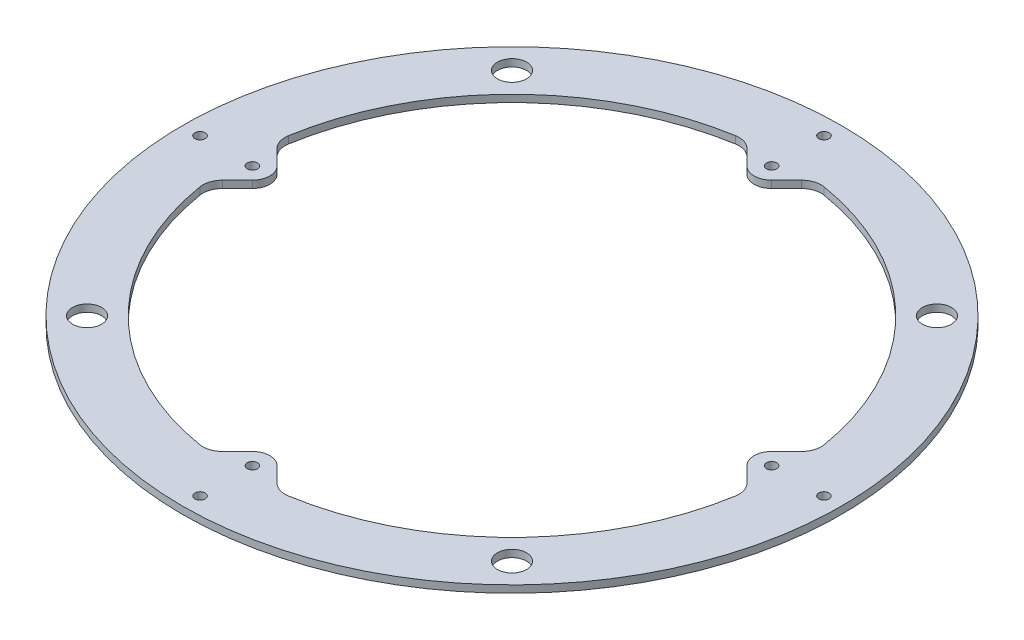
from build123d import *

# Parameters (mm, degrees)
SKETCH1_R                        = 215.9
SKETCH1_R_2                      = 177.8
BOSS_EXTRUDE1_DEPTH              = 4.7498
BOSS_EXTRUDE2_DEPTH              = 4.7498
FILLET2_R                        = 12.7
FILLET3_R                        = 11.43
F_1_4_CLEARANCE_HOLE1_AT_2_COUNT = 2
F_1_4_CLEARANCE_HOLE1_AT_2_PITCH = 34.29
CIRPATTERN1_COUNT                = 4
FILLET2_OF_CIRPATTERN1_R         = 12.7
FILLET3_OF_CIRPATTERN1_R         = 11.43
SKETCH6_R                        = 9.525
CUT_EXTRUDE1_DEPTH               = 4.7498
CIRPATTERN2_COUNT                = 4


with BuildPart() as part:
    # Sketch1 → Boss-Extrude1 (new body)
    with BuildSketch(Plane(origin=(0, 0, 0), x_dir=(1, 0, 0), z_dir=(0, 1, 0))):
        Circle(SKETCH1_R)
        Circle(SKETCH1_R_2, mode=Mode.SUBTRACT)
    extrude(amount=BOSS_EXTRUDE1_DEPTH)

    # Sketch3 → Boss-Extrude2 (add)
    with BuildSketch(Plane(origin=(0, 0, 0), x_dir=(1, 0, 0), z_dir=(0, 1, 0))):
        with BuildLine():
            Line((-22.450640303, 176.376894037), (0, 153.926253734))
            Line((0, 153.926253734), (22.450640303, 176.376894037))
            ThreePointArc((22.450640303, 176.376894037), (0, 177.8), (-22.450640303, 176.376894037))
        make_face()
    boss_extrude2 = extrude(amount=BOSS_EXTRUDE2_DEPTH)

    # Fillet2
    fillet2_edges = [part.edges().sort_by_distance(p)[0] for p in [
        (22.450640303, 2.3749, -176.376894037),
        (-22.450640303, 2.3749, -176.376894037),
    ]]
    fillet(fillet2_edges, radius=FILLET2_R)

    # Fillet3
    fillet3_edges = [part.edges().sort_by_distance(p)[0] for p in [
        (0, 2.3749, -153.926253734),
    ]]
    fillet(fillet3_edges, radius=FILLET3_R)

    # Sketch5 → 1/4 Clearance Hole1 (revolve, cut)
    with BuildSketch(Plane(origin=(0, 4.7498, -170.090714752), x_dir=(0, 0, 1), z_dir=(1, 0, 0))):
        Polygon((0, 0), (0, 12.189827343), (3.3782, 10.16), (3.3782, 0), align=None)
    f_1_4_clearance_hole1 = revolve(axis=Axis((0, 11.0998, -170.090714752), (0, -1, 0)), mode=Mode.SUBTRACT)

    # 1/4 Clearance Hole1 at 2: 1/4 Clearance Hole1 ×2
    with Locations(*[(0, 0, -i * F_1_4_CLEARANCE_HOLE1_AT_2_PITCH) for i in range(1, F_1_4_CLEARANCE_HOLE1_AT_2_COUNT)]):
        add(f_1_4_clearance_hole1, mode=Mode.SUBTRACT)

    # CirPattern1: Boss-Extrude2, 1/4 Clearance Hole1 ×4 about axis
    cirpattern1_axis = Axis((0, 0, 0), (0, 1, 0))
    for i in range(1, CIRPATTERN1_COUNT):
        add(boss_extrude2.rotate(cirpattern1_axis, i * 360 / CIRPATTERN1_COUNT))
        add(f_1_4_clearance_hole1.rotate(cirpattern1_axis, i * 360 / CIRPATTERN1_COUNT), mode=Mode.SUBTRACT)

    # CirPattern1 copy 1 sketch → CirPattern1 copy 1 (revolve, cut)
    with BuildSketch(Plane(origin=(-204.380714752, 4.7498, 0), x_dir=(1, 0, 0), z_dir=(0, 0, -1))):
        Polygon((0, 0), (0, 12.189827343), (3.3782, 10.16), (3.3782, 0), align=None)
    revolve(axis=Axis((-204.380714752, 11.0998, 0), (0, -1, 0)), mode=Mode.SUBTRACT)

    # CirPattern1 copy 2 sketch → CirPattern1 copy 2 (revolve, cut)
    with BuildSketch(Plane(origin=(0, 4.7498, 204.380714752), x_dir=(0, 0, -1), z_dir=(-1, 0, 0))):
        Polygon((0, 0), (0, 12.189827343), (3.3782, 10.16), (3.3782, 0), align=None)
    revolve(axis=Axis((0, 11.0998, 204.380714752), (0, -1, 0)), mode=Mode.SUBTRACT)

    # CirPattern1 copy 3 sketch → CirPattern1 copy 3 (revolve, cut)
    with BuildSketch(Plane(origin=(204.380714752, 4.7498, 0), x_dir=(-1, 0, 0), z_dir=(0, 0, 1))):
        Polygon((0, 0), (0, 12.189827343), (3.3782, 10.16), (3.3782, 0), align=None)
    revolve(axis=Axis((204.380714752, 11.0998, 0), (0, -1, 0)), mode=Mode.SUBTRACT)

    # Fillet2 of CirPattern1
    fillet2_of_cirpattern1_edges = [part.edges().sort_by_distance(p)[0] for p in [
        (-176.376894037, 2.3749, -22.450640303),
        (-176.376894037, 2.3749, 22.450640303),
        (-22.450640303, 2.3749, 176.376894037),
        (22.450640303, 2.3749, 176.376894037),
        (176.376894037, 2.3749, 22.450640303),
        (176.376894037, 2.3749, -22.450640303),
    ]]
    fillet(fillet2_of_cirpattern1_edges, radius=FILLET2_OF_CIRPATTERN1_R)

    # Fillet3 of CirPattern1
    fillet3_of_cirpattern1_edges = [part.edges().sort_by_distance(p)[0] for p in [
        (-153.926253734, 2.3749, 0),
        (0, 2.3749, 153.926253734),
        (153.926253734, 2.3749, 0),
    ]]
    fillet(fillet3_of_cirpattern1_edges, radius=FILLET3_OF_CIRPATTERN1_R)

    # Sketch6 → Cut-Extrude1 (cut)
    with BuildSketch(Plane(origin=(0, 4.7498, 0), x_dir=(1, 0, 0), z_dir=(0, 1, 0))):
        with Locations((-139.193969877, 139.193969877)):
            Circle(SKETCH6_R)
    cut_extrude1 = extrude(amount=-CUT_EXTRUDE1_DEPTH, mode=Mode.SUBTRACT)

    # CirPattern2: Cut-Extrude1 ×4 about axis
    cirpattern2_axis = Axis((0, 0, 0), (0, 1, 0))
    for i in range(1, CIRPATTERN2_COUNT):
        add(cut_extrude1.rotate(cirpattern2_axis, i * 360 / CIRPATTERN2_COUNT), mode=Mode.SUBTRACT)


solid = part.part
